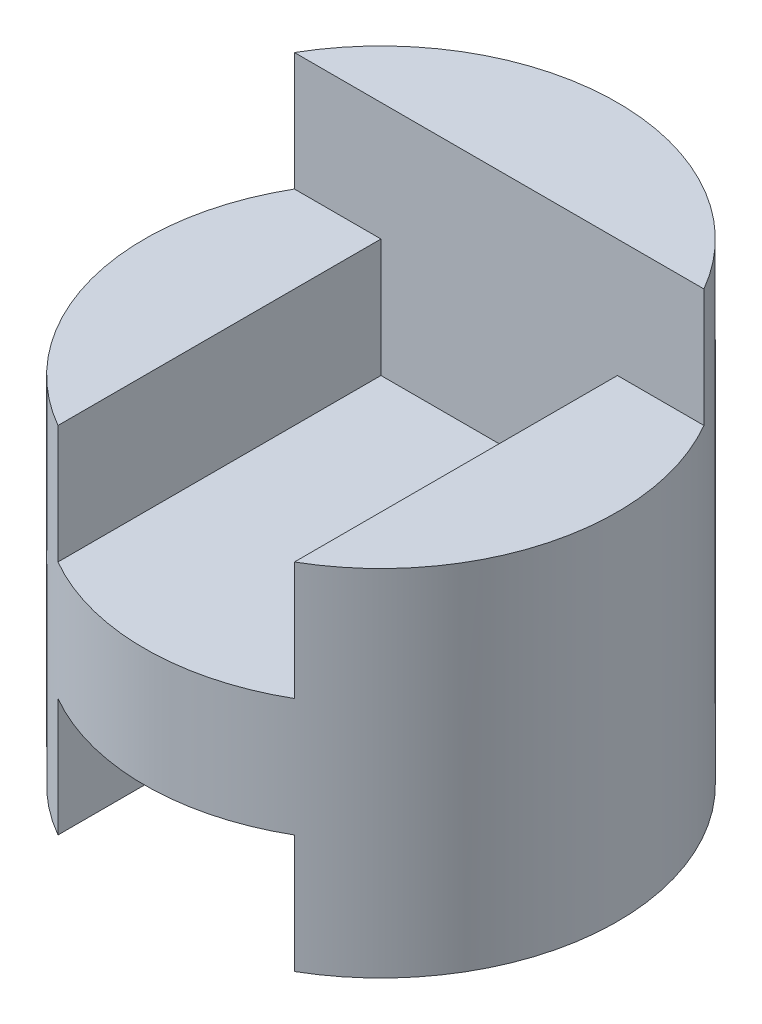
from build123d import *

# Parameters (mm, degrees)
SKETCH1_R               = 2
BOSS_EXTRUDE1_DEPTH     = 4
SKETCH2_W               = 2
SKETCH2_H               = 1
CUT_EXTRUDE1_DEPTH      = 3
CUT_EXTRUDE1_DEPTH_BACK = 1


with BuildPart() as part:
    # Sketch1 → Boss-Extrude1 (new body)
    with BuildSketch(Plane(origin=(0, 0, 0), x_dir=(1, 0, 0), z_dir=(0, 1, 0))):
        Circle(SKETCH1_R)
    extrude(amount=BOSS_EXTRUDE1_DEPTH)

    # Sketch2 → Cut-Extrude1 (cut, two sides)
    with BuildSketch(Plane.XY) as cut_extrude1_sk:
        Polygon((-2, 4), (2, 4), (2, 3), (1, 3), (1, 2), (-1, 2), (-1, 3), (-2, 3), align=None)
        with Locations((0, 0.5)):
            Rectangle(SKETCH2_W, SKETCH2_H)
    extrude(amount=CUT_EXTRUDE1_DEPTH, mode=Mode.SUBTRACT)
    extrude(cut_extrude1_sk.sketch, amount=-CUT_EXTRUDE1_DEPTH_BACK, mode=Mode.SUBTRACT)


solid = part.part
